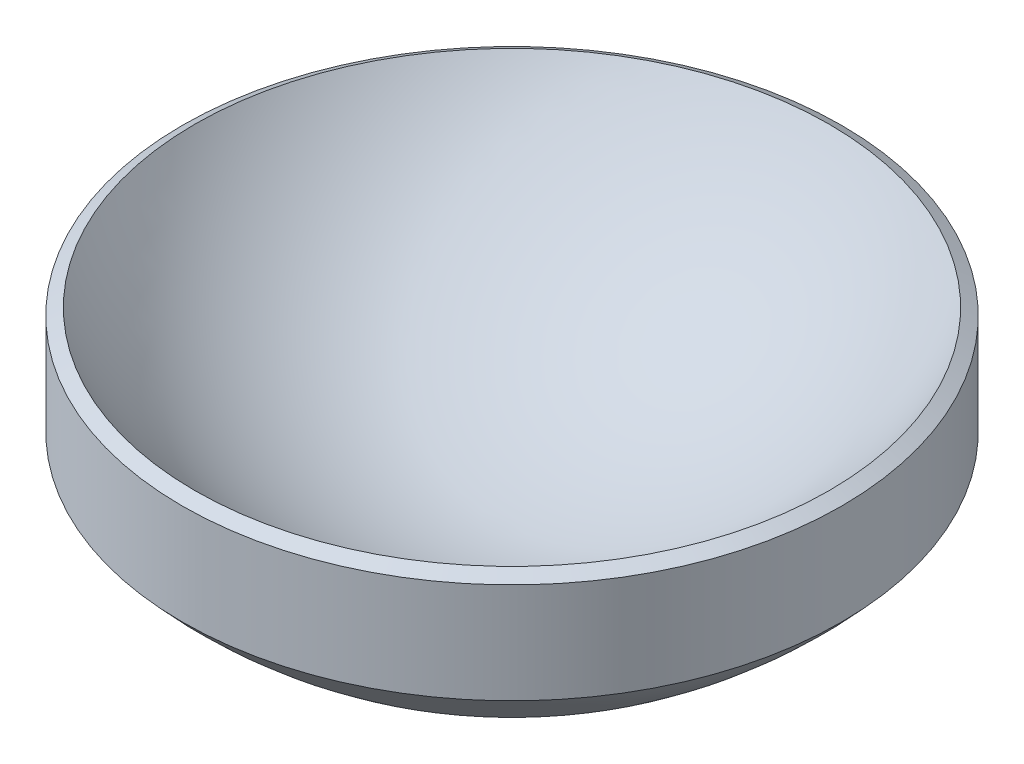
from build123d import *

# Parameters (mm, degrees)
SKETCH_2_W               = 1.902691091
SKETCH_2_H               = 5.293337887
SKETCH_3_W               = 11.904020265
SKETCH_3_H               = 2.403246825
CUT_EXTRUDE_1_DEPTH      = 5.5
CUT_EXTRUDE_1_DEPTH_BACK = 5.5


with BuildPart() as part:
    # Эскиз1 one side → Повернуть1 (revolve)
    with BuildSketch(Plane.XY):
        with BuildLine():
            Line((0, 0), (0, -1))
            ThreePointArc((0, -1), (3, -0.196152423), (5.196152423, 2))
            Line((5.196152423, 2), (4.330127019, 2.5))
            ThreePointArc((4.330127019, 2.5), (2.5, 0.669872981), (0, 0))
        make_face()
    revolve(axis=Axis((0, 0, 0), (0, -1, 0)))

    # Эскиз2 → Вырез-Повернуть1 (revolve, cut)
    with BuildSketch(Plane.XY):
        with Locations((-5.451345546, 1.418725327)):
            Rectangle(SKETCH_2_W, SKETCH_2_H)
    revolve(axis=Axis((0, 0, 0), (0, 1, 0)), mode=Mode.SUBTRACT)

    # Эскиз3 → Вырез-Вытянуть1 (cut, two sides)
    with BuildSketch(Plane.XY) as cut_extrude_1_sk:
        with Locations((-0.172996367, -1.901623413)):
            Rectangle(SKETCH_3_W, SKETCH_3_H)
    extrude(amount=CUT_EXTRUDE_1_DEPTH, mode=Mode.SUBTRACT)
    extrude(cut_extrude_1_sk.sketch, amount=-CUT_EXTRUDE_1_DEPTH_BACK, mode=Mode.SUBTRACT)


solid = part.part
